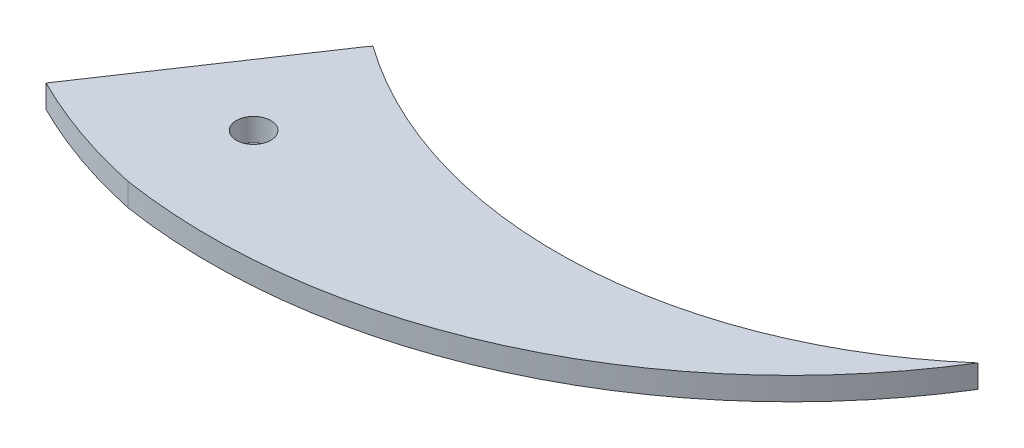
from build123d import *

# Parameters (mm, degrees)
BOSS_EXTRUDE2_DEPTH = 1
SKETCH6_R           = 0.75
CUT_EXTRUDE3_DEPTH  = 10


with BuildPart() as part:
    # Sketch4 → Boss-Extrude2 (new body)
    with BuildSketch(Plane(origin=(0, 0, 0), x_dir=(1, 0, 0), z_dir=(0, 1, 0))):
        with BuildLine():
            Line((-19.253709209, -12.655761176), (-13.682264454, -4.351605389))
            ThreePointArc((-13.682264454, -4.351605389), (-13.599577219, -4.243463868), (-13.518155162, -4.134366591))
            ThreePointArc((-13.518155162, -4.134366591), (-0.727323966, -7.891124567), (11.63634616, -2.905319296))
            ThreePointArc((11.63634616, -2.905319296), (0.692257999, -12.564498934), (-13.765160625, -14.578416434))
            ThreePointArc((-13.765160625, -14.578416434), (-16.57001445, -13.790023452), (-19.253709209, -12.655761176))
        make_face()
    extrude(amount=BOSS_EXTRUDE2_DEPTH)

    # Sketch6 → Cut-Extrude3 (cut)
    with BuildSketch(Plane(origin=(0, 1, 0), x_dir=(1, 0, 0), z_dir=(0, 1, 0))):
        with Locations((-12.937427019, -9.919909774)):
            Circle(SKETCH6_R)
    extrude(amount=-CUT_EXTRUDE3_DEPTH, mode=Mode.SUBTRACT)


solid = part.part
